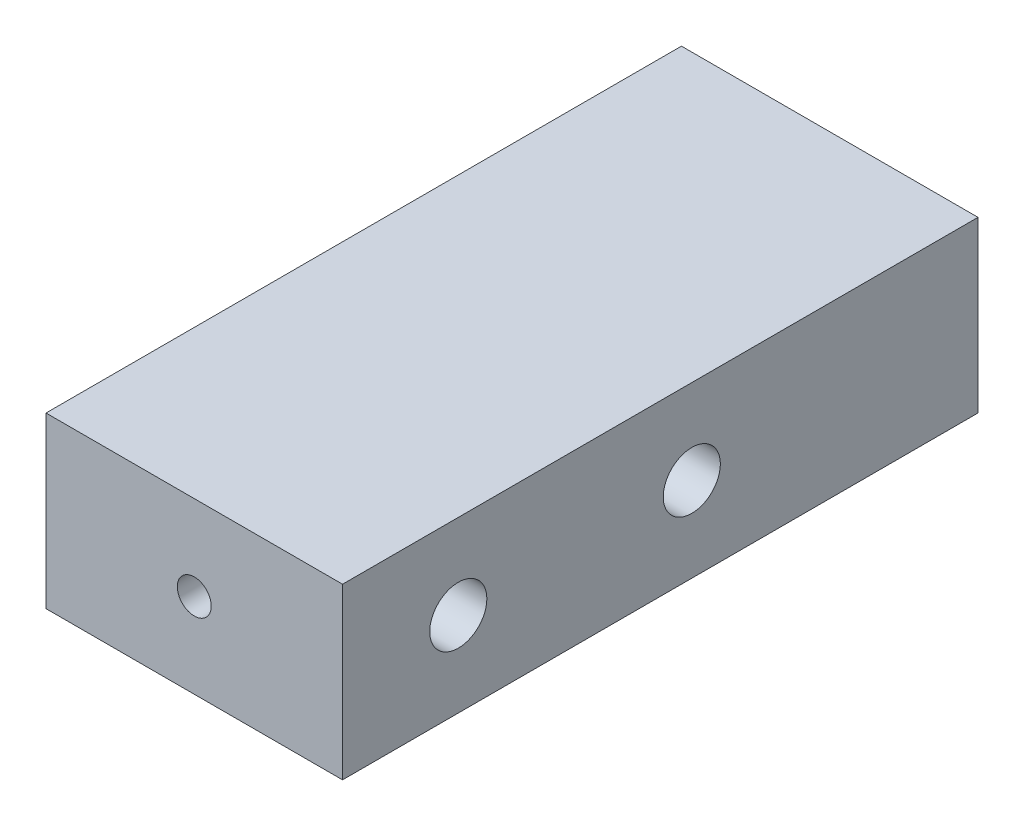
from build123d import *

# Parameters (mm, degrees)
SKETCH1_W           = 44.45
SKETCH1_H           = 25.4
BOSS_EXTRUDE1_DEPTH = 95.25
SKETCH2_R           = 4.28
CUT_EXTRUDE1_DEPTH  = 14.224
SKETCH3_R           = 4.28
CUT_EXTRUDE2_DEPTH  = 14.224
SKETCH5_R           = 4.2799
CUT_EXTRUDE4_DEPTH  = 14.224
SKETCH6_R           = 2.54
CUT_EXTRUDE5_DEPTH  = 86.36
CUT_EXTRUDE6_REACH  = 32.226
SKETCH7_R           = 2.54
CUT_EXTRUDE7_REACH  = 32.226
SKETCH8_R           = 2.54


with BuildPart() as part:
    # Sketch1 → Boss-Extrude1 (new body)
    with BuildSketch(Plane.XY):
        with Locations((22.225, 12.7)):
            Rectangle(SKETCH1_W, SKETCH1_H)
    extrude(amount=BOSS_EXTRUDE1_DEPTH)

    # Sketch2 → Cut-Extrude1 (cut)
    with BuildSketch(Plane.ZY):
        with Locations((25.4, 12.7)):
            Circle(SKETCH2_R)
        with Locations((60.4, 12.7)):
            Circle(SKETCH2_R)
    extrude(amount=-CUT_EXTRUDE1_DEPTH, mode=Mode.SUBTRACT)

    # Sketch3 → Cut-Extrude2 (cut)
    with BuildSketch(Plane(origin=(44.45, 0, 0), x_dir=(0, 0, -1), z_dir=(1, 0, 0))):
        with Locations((-77.9, 12.7)):
            Circle(SKETCH3_R)
        with Locations((-42.9, 12.7)):
            Circle(SKETCH3_R)
    extrude(amount=-CUT_EXTRUDE2_DEPTH, mode=Mode.SUBTRACT)

    # Sketch5 → Cut-Extrude4 (cut)
    with BuildSketch(Plane(origin=(0, 0, 0), x_dir=(-1, 0, 0), z_dir=(0, 0, -1))):
        with Locations((-22.225, 12.7)):
            Circle(SKETCH5_R)
    extrude(amount=-CUT_EXTRUDE4_DEPTH, mode=Mode.SUBTRACT)

    # Sketch6 → Cut-Extrude5 (cut)
    with BuildSketch(Plane(origin=(0, 0, 14.224), x_dir=(-1, 0, 0), z_dir=(0, 0, -1))):
        with Locations((-22.225, 12.7)):
            Circle(SKETCH6_R)
    extrude(amount=-CUT_EXTRUDE5_DEPTH, mode=Mode.SUBTRACT)

    # Sketch7 → Cut-Extrude6 (cut, up to next)
    with BuildSketch(Plane(origin=(30.226, 0, 0), x_dir=(0, 0, -1), z_dir=(1, 0, 0)), mode=Mode.PRIVATE) as cut_extrude6_sk1:
        with Locations((-42.9, 12.7)):
            Circle(SKETCH7_R)
    cut_extrude6_tool1 = extrude(cut_extrude6_sk1.sketch, amount=-CUT_EXTRUDE6_REACH, mode=Mode.PRIVATE) & part.part
    add(cut_extrude6_tool1.solids().sort_by_distance((30.226, 12.7, 42.9))[0], mode=Mode.SUBTRACT)
    # Sketch7 → Cut-Extrude6 (cut, up to next)
    with BuildSketch(Plane(origin=(30.226, 0, 0), x_dir=(0, 0, -1), z_dir=(1, 0, 0)), mode=Mode.PRIVATE) as cut_extrude6_sk2:
        with Locations((-77.9, 12.7)):
            Circle(SKETCH7_R)
    cut_extrude6_tool2 = extrude(cut_extrude6_sk2.sketch, amount=-CUT_EXTRUDE6_REACH, mode=Mode.PRIVATE) & part.part
    add(cut_extrude6_tool2.solids().sort_by_distance((30.226, 12.7, 77.9))[0], mode=Mode.SUBTRACT)

    # Sketch8 → Cut-Extrude7 (cut, up to next)
    with BuildSketch(Plane.ZY.offset(-14.224), mode=Mode.PRIVATE) as cut_extrude7_sk1:
        with Locations((25.4, 12.7)):
            Circle(SKETCH8_R)
    cut_extrude7_tool1 = extrude(cut_extrude7_sk1.sketch, amount=-CUT_EXTRUDE7_REACH, mode=Mode.PRIVATE) & part.part
    add(cut_extrude7_tool1.solids().sort_by_distance((14.224, 12.7, 25.4))[0], mode=Mode.SUBTRACT)
    # Sketch8 → Cut-Extrude7 (cut, up to next)
    with BuildSketch(Plane.ZY.offset(-14.224), mode=Mode.PRIVATE) as cut_extrude7_sk2:
        with Locations((60.4, 12.7)):
            Circle(SKETCH8_R)
    cut_extrude7_tool2 = extrude(cut_extrude7_sk2.sketch, amount=-CUT_EXTRUDE7_REACH, mode=Mode.PRIVATE) & part.part
    add(cut_extrude7_tool2.solids().sort_by_distance((14.224, 12.7, 60.4))[0], mode=Mode.SUBTRACT)


solid = part.part
